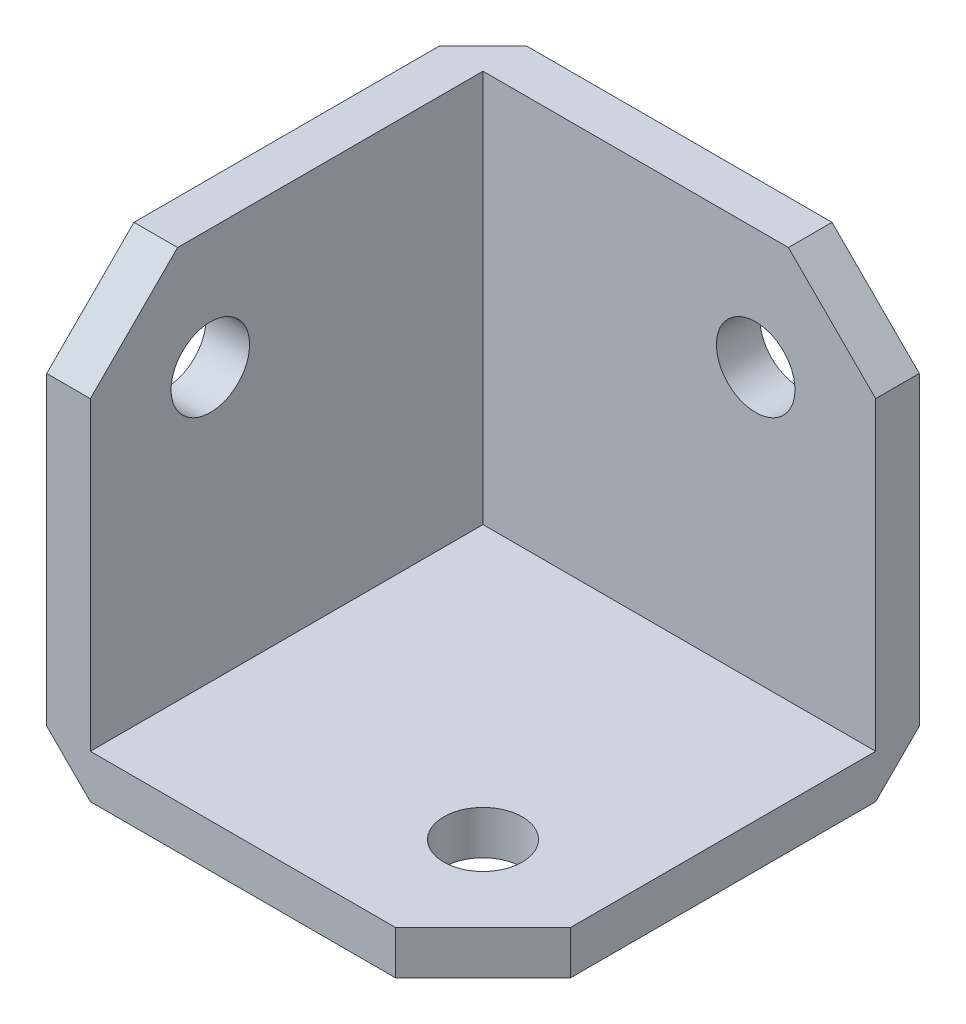
from build123d import *

# Parameters (mm, degrees)
SKETCH2_W           = 25.4
SKETCH2_H           = 25.4
BOSS_EXTRUDE2_DEPTH = 25.4
SKETCH3_W           = 22.86
SKETCH3_H           = 22.86
CUT_EXTRUDE1_DEPTH  = 22.86
SKETCH4_R           = 2.286
CUT_EXTRUDE3_DEPTH  = 2.54
SKETCH5_R           = 2.286
CUT_EXTRUDE4_DEPTH  = 2.54
SKETCH6_R           = 2.286
CUT_EXTRUDE5_DEPTH  = 2.54
CHAMFER1_SIZE       = 5.08
CHAMFER2_SIZE       = 2.54


with BuildPart() as part:
    # Sketch2 → Boss-Extrude2 (new body)
    with BuildSketch(Plane.XY):
        with Locations((12.7, 12.7)):
            Rectangle(SKETCH2_W, SKETCH2_H)
    extrude(amount=BOSS_EXTRUDE2_DEPTH)

    # Sketch3 → Cut-Extrude1 (cut)
    with BuildSketch(Plane.XY.offset(25.4)):
        with Locations((13.97, 13.97)):
            Rectangle(SKETCH3_W, SKETCH3_H)
    extrude(amount=-CUT_EXTRUDE1_DEPTH, mode=Mode.SUBTRACT)

    # Sketch4 → Cut-Extrude3 (cut)
    with BuildSketch(Plane.XY.offset(2.54)):
        with Locations((18.415, 18.415)):
            Circle(SKETCH4_R)
    extrude(amount=-CUT_EXTRUDE3_DEPTH, mode=Mode.SUBTRACT)

    # Sketch5 → Cut-Extrude4 (cut)
    with BuildSketch(Plane(origin=(2.54, 0, 0), x_dir=(0, 0, -1), z_dir=(1, 0, 0))):
        with Locations((-18.415, 18.415)):
            Circle(SKETCH5_R)
    extrude(amount=-CUT_EXTRUDE4_DEPTH, mode=Mode.SUBTRACT)

    # Sketch6 → Cut-Extrude5 (cut)
    with BuildSketch(Plane(origin=(0, 2.54, 0), x_dir=(1, 0, 0), z_dir=(0, 1, 0))):
        with Locations((18.415, -18.415)):
            Circle(SKETCH6_R)
    extrude(amount=-CUT_EXTRUDE5_DEPTH, mode=Mode.SUBTRACT)

    # Chamfer1
    chamfer1_edges = [part.edges().sort_by_distance(p)[0] for p in [
        (25.4, 1.27, 25.4),
        (1.27, 25.4, 25.4),
        (25.4, 25.4, 1.27),
    ]]
    chamfer(chamfer1_edges, length=CHAMFER1_SIZE)

    # Chamfer2
    chamfer2_edges = [part.edges().sort_by_distance(p)[0] for p in [
        (12.7, 0, 0),
        (0, 12.7, 0),
        (0, 0, 12.7),
    ]]
    chamfer(chamfer2_edges, length=CHAMFER2_SIZE)


solid = part.part
